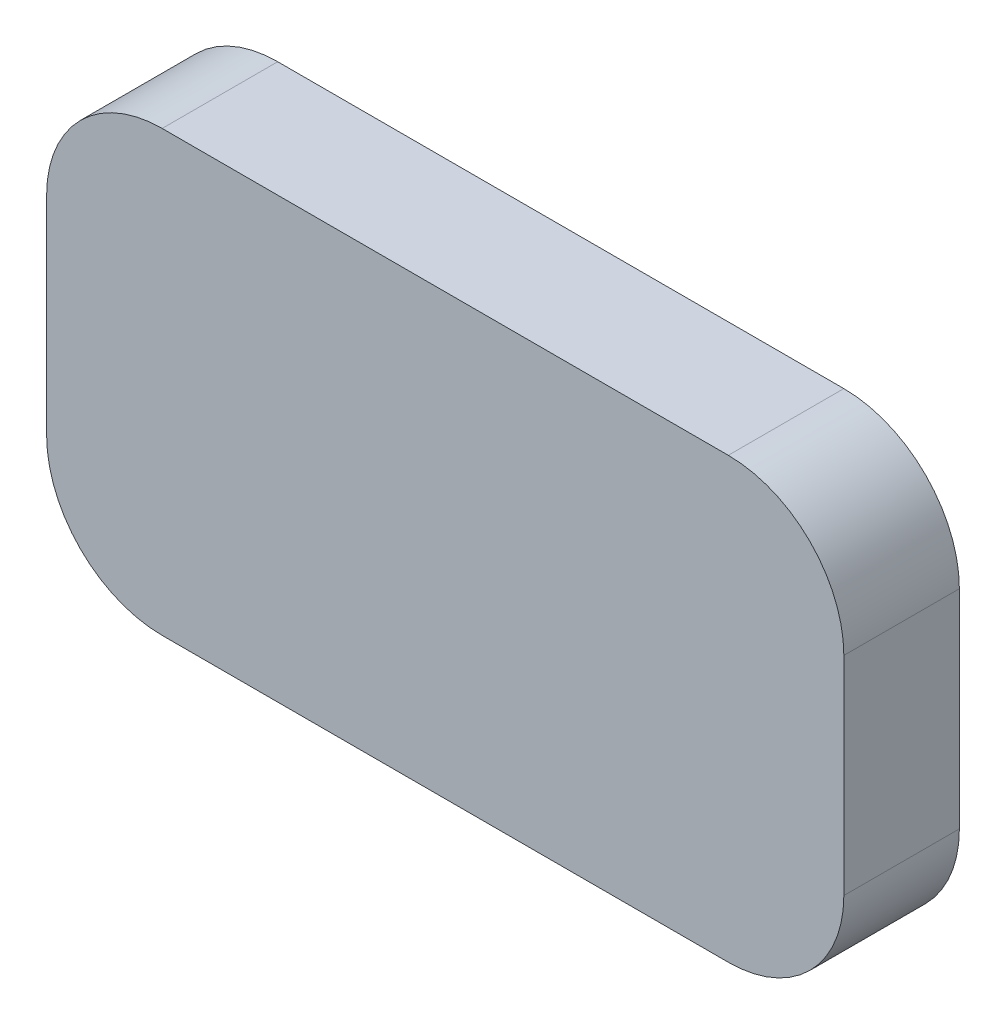
from build123d import *

# Parameters (mm, degrees)
SKETCH1_W           = 69
SKETCH1_H           = 38
BOSS_EXTRUDE1_DEPTH = 10
FILLET1_R           = 10


with BuildPart() as part:
    # Sketch1 → Boss-Extrude1 (new body)
    with BuildSketch(Plane.XY):
        with Locations((34.5, -19)):
            Rectangle(SKETCH1_W, SKETCH1_H)
    extrude(amount=BOSS_EXTRUDE1_DEPTH)

    # Fillet1
    fillet1_edges = [part.edges().sort_by_distance(p)[0] for p in [
        (0, 0, 5),
        (69, 0, 5),
        (69, -38, 5),
        (0, -38, 5),
    ]]
    fillet(fillet1_edges, radius=FILLET1_R)


solid = part.part
